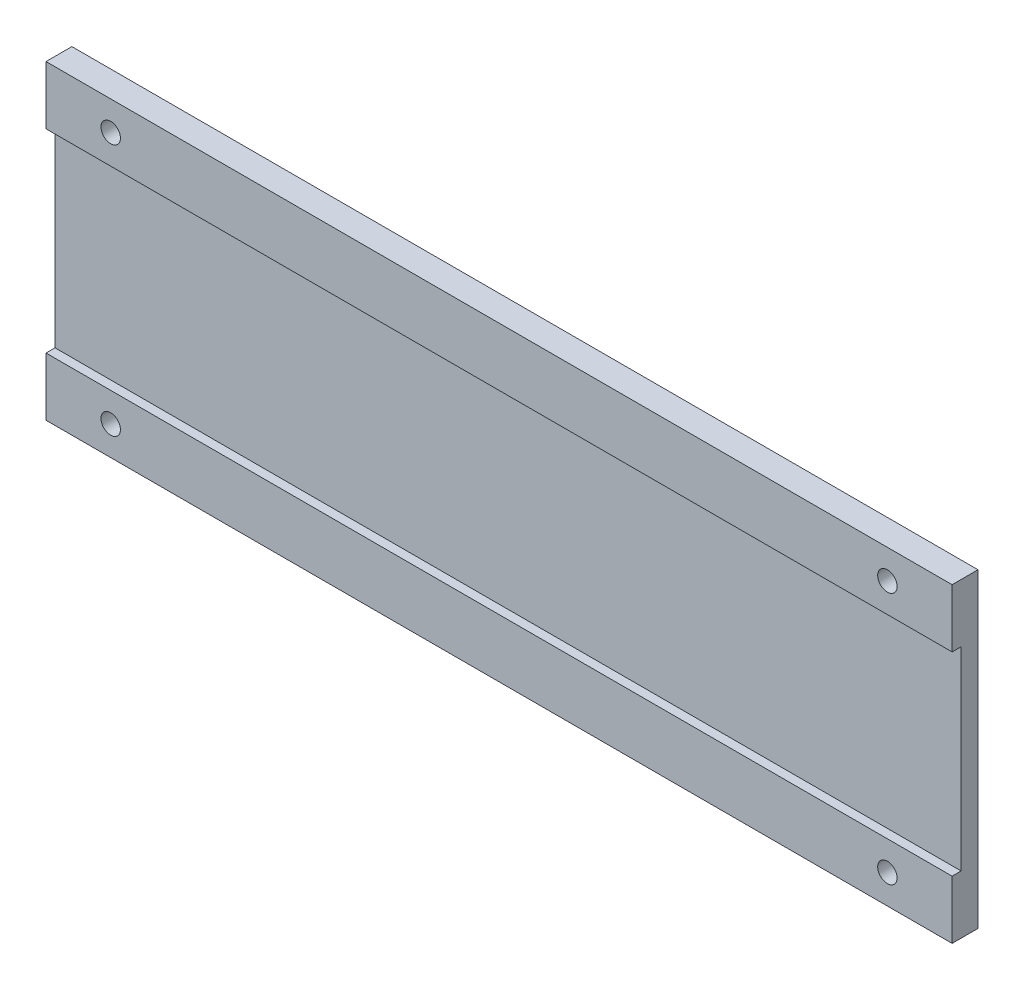
from build123d import *

# Parameters (mm, degrees)
ESQUISSE1_W             = 140
ESQUISSE1_H             = 48
BOSS_EXTRU_1_DEPTH      = 4
ESQUISSE2_W             = 1.390122209
ESQUISSE2_H             = 30
ENL_V_MAT_EXTRU_1_DEPTH = 141
ESQUISSE4_R             = 1.5
ENL_V_MAT_EXTRU_3_DEPTH = 6


with BuildPart() as part:
    # Esquisse1 → Boss.-Extru.1 (new body)
    with BuildSketch(Plane.XY):
        with Locations((36.441041546, 1.939393939)):
            Rectangle(ESQUISSE1_W, ESQUISSE1_H)
    extrude(amount=BOSS_EXTRU_1_DEPTH)

    # Esquisse2 → Enlèv. mat.-Extru.1 (cut, through all)
    with BuildSketch(Plane.ZY.offset(33.558958454)):
        with Locations((3.304938896, 1.939393939)):
            Rectangle(ESQUISSE2_W, ESQUISSE2_H)
    extrude(amount=-ENL_V_MAT_EXTRU_1_DEPTH, mode=Mode.SUBTRACT)

    # Esquisse4 → Enlèv. mat.-Extru.3 (cut)
    with BuildSketch(Plane.XY.offset(4)):
        with Locations((-23.558958454, 21.439393939)):
            Circle(ESQUISSE4_R)
        with Locations((96.441041546, 21.439393939)):
            Circle(ESQUISSE4_R)
        with Locations((-23.558958454, -17.560606061)):
            Circle(ESQUISSE4_R)
        with Locations((96.441041546, -17.560606061)):
            Circle(ESQUISSE4_R)
    extrude(amount=-ENL_V_MAT_EXTRU_3_DEPTH, mode=Mode.SUBTRACT)


solid = part.part
